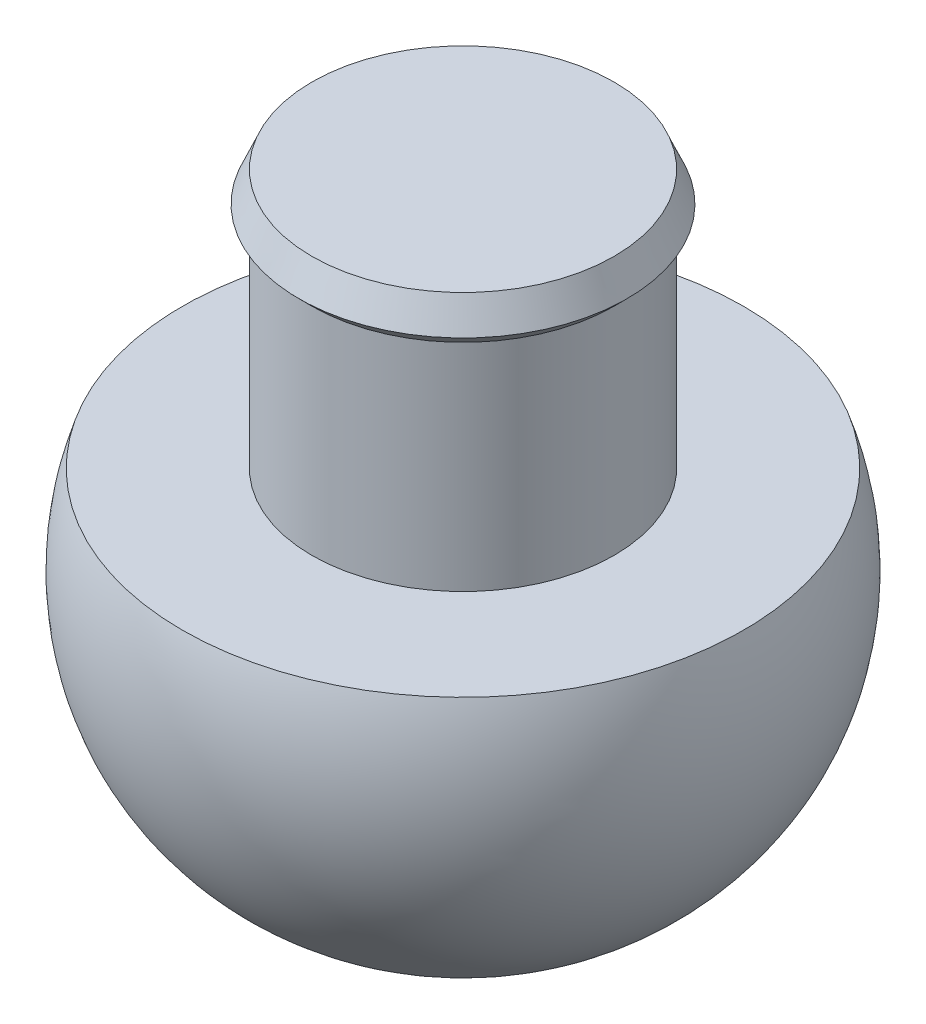
from build123d import *


with BuildPart() as part:
    # Sketch1 → Revolve2 (revolve)
    with BuildSketch(Plane.XY):
        with BuildLine():
            Line((-3.5, 1.609945363), (-3.5, -3.390054637))
            Line((-3.5, -3.390054637), (-6.5, -3.390054637))
            ThreePointArc((-6.5, -3.390054637), (-5.503659161, -9.365627215), (0, -11.897404959))
            Line((0, -11.897404959), (0, 2.609945363))
            Line((0, 2.609945363), (-3.5, 2.609945363))
            Line((-3.5, 2.609945363), (-3.8, 1.909945363))
            Line((-3.8, 1.909945363), (-3.5, 1.609945363))
        make_face()
    revolve(axis=Axis((0, -11.897404959, 0), (0, 1, 0)))


solid = part.part
